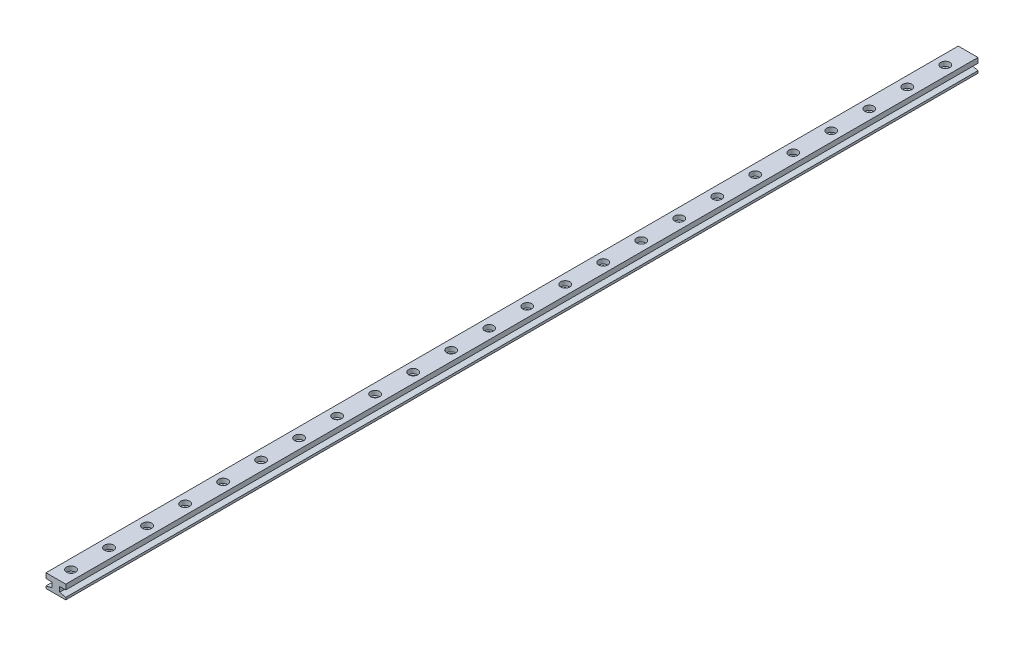
from build123d import *

# Parameters (mm, degrees)
EXTRUDE_1_DEPTH        = 600
SKETCH_2_R             = 3
CUT_EXTRUDE_1_DEPTH    = 3
SKETCH_3_R             = 1.6
CUT_EXTRUDE_2_DEPTH    = 6
PATTERN_LINEAR_1_COUNT = 24
PATTERN_LINEAR_1_PITCH = 25


with BuildPart() as part:
    # 草图1 → 凸台-拉伸1 (new body)
    with BuildSketch(Plane.XY):
        Polygon((-6.5, 4.5), (6.5, 4.5), (6.5, 1.2), (2.5, 1.2), (2.5, -2.076527235), (6.5, -3), (6.5, -4.5), (-6.5, -4.5), (-6.5, -3), (-2.5, -2.076527235), (-2.5, 1.2), (-6.5, 1.2), align=None)
    extrude(amount=EXTRUDE_1_DEPTH)

    # 草图2 → 切除-拉伸1 (cut)
    with BuildSketch(Plane(origin=(0, 4.5, 0), x_dir=(1, 0, 0), z_dir=(0, 1, 0))):
        with Locations((0, -590)):
            Circle(SKETCH_2_R)
    cut_extrude_1 = extrude(amount=-CUT_EXTRUDE_1_DEPTH, mode=Mode.SUBTRACT)

    # 草图3 → 切除-拉伸2 (cut)
    with BuildSketch(Plane(origin=(0, 1.5, 0), x_dir=(1, 0, 0), z_dir=(0, 1, 0))):
        with Locations((0, -590)):
            Circle(SKETCH_3_R)
    cut_extrude_2 = extrude(amount=-CUT_EXTRUDE_2_DEPTH, mode=Mode.SUBTRACT)

    # 阵列(线性)1: 切除-拉伸1, 切除-拉伸2 ×24
    with Locations(*[(0, 0, -i * PATTERN_LINEAR_1_PITCH) for i in range(1, PATTERN_LINEAR_1_COUNT)]):
        add(cut_extrude_1, mode=Mode.SUBTRACT)
        add(cut_extrude_2, mode=Mode.SUBTRACT)


solid = part.part
